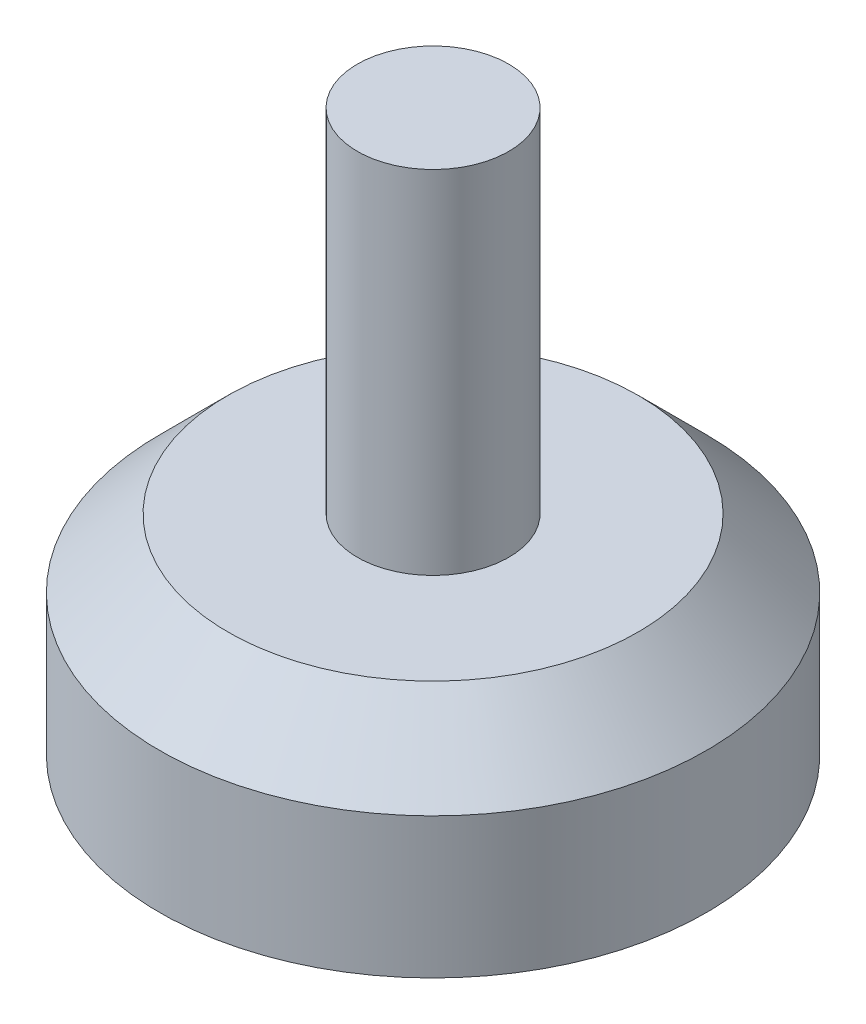
from build123d import *


with BuildPart() as part:
    # Sketch6 → Revolve2 (revolve)
    with BuildSketch(Plane.XY, mode=Mode.PRIVATE) as revolve2_sk:
        Polygon((0, 90.269769418), (0, 0), (-44.053220805, 0), (-44.053220805, 22.616608895), (-33.039915604, 33.629914097), (-12.193302187, 33.629914097), (-12.193302187, 90.269769418), align=None)
    revolve(revolve2_sk.sketch.rotate(Axis((0, 0, 0), (0, 1, 0)), 270), axis=Axis((0, 0, 0), (0, 1, 0)))  # turned: the seam where the file's is


solid = part.part
